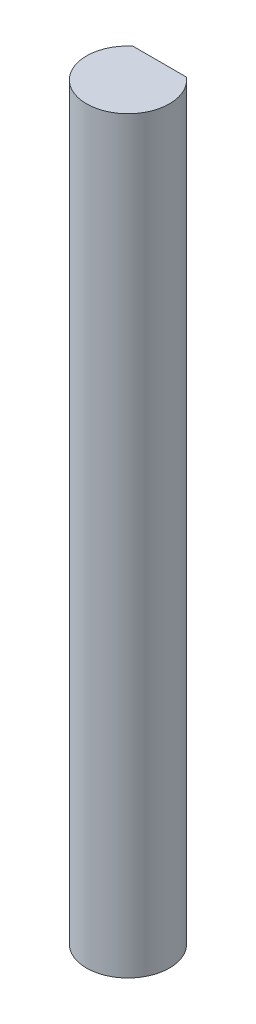
from build123d import *

# Parameters (mm, degrees)
BOSS_EXTRUDE1_DEPTH = 28.575


with BuildPart() as part:
    # Sketch1 → Boss-Extrude1 (new body, symmetric)
    with BuildSketch(Plane(origin=(0, 0, 0), x_dir=(1, 0, 0), z_dir=(0, 1, 0))):
        with BuildLine():
            Line((-2.049236991, 2.41681), (2.049236991, 2.41681))
            ThreePointArc((2.049236991, 2.41681), (0, -3.16865), (-2.049236991, 2.41681))
        make_face()
    extrude(amount=BOSS_EXTRUDE1_DEPTH, both=True)


solid = part.part
